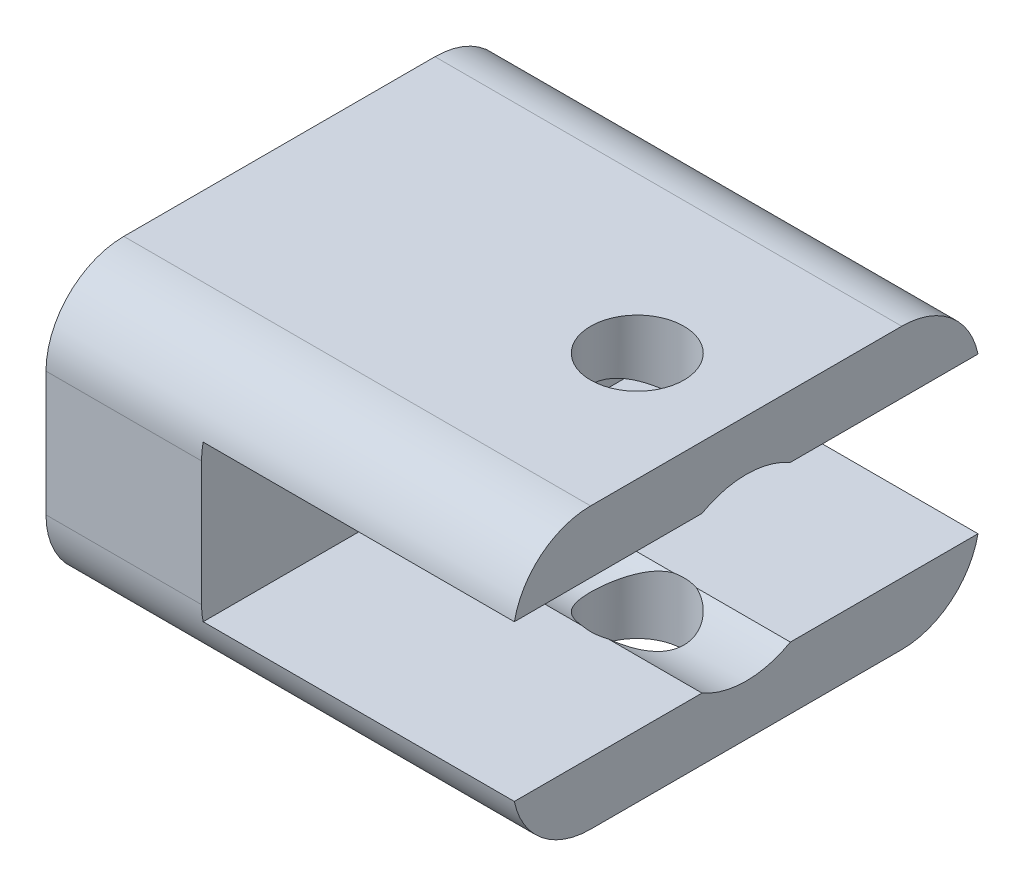
from build123d import *

# Parameters (mm, degrees)
ESQUISSE1_W                        = 30
ESQUISSE1_H                        = 30
BOSS_EXTRU_1_DEPTH                 = 4
ENL_V_MAT_EXTRU_1_DEPTH            = 12.400000001
ESQUISSE3_W                        = 10
ESQUISSE3_H                        = 30
BOSS_EXTRU_2_DEPTH                 = 14
ESQUISSE4_W                        = 30
ESQUISSE4_H                        = 4
BOSS_EXTRU_3_DEPTH                 = 20
ESQUISSE5_R                        = 5.75
ENL_V_MAT_EXTRU_2_DEPTH            = 20
DIAM_TRE_DU_PER_AGE_6_0_6_1_REACH  = 20
DIAM_TRE_DU_PER_AGE_6_0_6_1_BORE_R = 3
DIAM_TRE_DU_PER_AGE_6_0_6_2_D      = 6
DIAM_TRE_DU_PER_AGE_6_0_6_2_DEPTH  = 18
CONG_2_R                           = 5


with BuildPart() as part:
    # Esquisse1 → Boss.-Extru.1 (new body)
    with BuildSketch(Plane.XZ):
        with Locations((15, 15)):
            Rectangle(ESQUISSE1_W, ESQUISSE1_H)
    extrude(amount=-BOSS_EXTRU_1_DEPTH)

    # Esquisse2 → Enlèv. mat.-Extru.1 (cut)
    with BuildSketch(Plane(origin=(22.400000001, 0, 0), x_dir=(0, 0, -1), z_dir=(1, 0, 0))):
        with BuildLine():
            Line((-12.060612309, 4), (-17.939387691, 4))
            ThreePointArc((-17.939387691, 4), (-15, 3.2), (-12.060612309, 4))
        make_face()
    extrude(amount=-ENL_V_MAT_EXTRU_1_DEPTH, mode=Mode.SUBTRACT)

    # Esquisse3 → Boss.-Extru.2 (add)
    with BuildSketch(Plane(origin=(0, 4, 0), x_dir=(-1, 0, 0), z_dir=(0, 1, 0))):
        with Locations((-5, 15)):
            Rectangle(ESQUISSE3_W, ESQUISSE3_H)
    extrude(amount=BOSS_EXTRU_2_DEPTH)

    # Esquisse4 → Boss.-Extru.3 (add)
    with BuildSketch(Plane(origin=(10, 0, 0), x_dir=(0, 0, -1), z_dir=(1, 0, 0))):
        with Locations((-15, 16)):
            Rectangle(ESQUISSE4_W, ESQUISSE4_H)
    extrude(amount=BOSS_EXTRU_3_DEPTH)

    # Esquisse5 → Enlèv. mat.-Extru.2 (cut)
    with BuildSketch(Plane(origin=(30, 0, 0), x_dir=(0, 0, -1), z_dir=(1, 0, 0))):
        with Locations((-15, 9)):
            Circle(ESQUISSE5_R)
    extrude(amount=-ENL_V_MAT_EXTRU_2_DEPTH, mode=Mode.SUBTRACT)

    # Esquisse7 → Enlèvement de matière-Révolution1 (revolve, cut)
    with BuildSketch(Plane(origin=(0, 0, 15), x_dir=(-1, 0, 0), z_dir=(0, 0, -1)), mode=Mode.PRIVATE) as enl_vement_de_mati_re_r_volution1_sk:
        Polygon((-10, 14.75), (-10, 9), (0, 9), (0, 11.75), (-7, 11.75), align=None)
    revolve(enl_vement_de_mati_re_r_volution1_sk.sketch.rotate(Axis((10, 9, 15), (-1, 0, 0)), 29.591845794), axis=Axis((10, 9, 15), (-1, 0, 0)), mode=Mode.SUBTRACT)  # turned: the seam where the file's is

    # Diamètre du perçage Ø6.0 (6)1 bore → Diamètre du perçage Ø6.0 (6)1 (cut, up to next)
    with BuildSketch(Plane(origin=(0, 18, 0), x_dir=(1, 0, 0), z_dir=(0, 1, 0)), mode=Mode.PRIVATE) as diam_tre_du_per_age_6_0_6_1_sk1:
        with Locations((23, -15)):
            Circle(DIAM_TRE_DU_PER_AGE_6_0_6_1_BORE_R)
    diam_tre_du_per_age_6_0_6_1_tool1 = extrude(diam_tre_du_per_age_6_0_6_1_sk1.sketch, amount=-DIAM_TRE_DU_PER_AGE_6_0_6_1_REACH, mode=Mode.PRIVATE) & part.part
    add(diam_tre_du_per_age_6_0_6_1_tool1.solids().sort_by_distance((23, 18, 15))[0], mode=Mode.SUBTRACT)

    # Diamètre du perçage Ø6.0 (6)2
    with Locations(Plane(origin=(0, 0, 0), x_dir=(-1, 0, 0), z_dir=(0, -1, 0))):
        with Locations((-23, -15)):
            Hole(DIAM_TRE_DU_PER_AGE_6_0_6_2_D / 2, depth=DIAM_TRE_DU_PER_AGE_6_0_6_2_DEPTH)

    # Congé2
    cong_2_edges = [part.edges().sort_by_distance(p)[0] for p in [
        (15, 18, 0),
        (15, 0, 0),
        (15, 0, 30),
        (15, 18, 30),
    ]]
    fillet(cong_2_edges, radius=CONG_2_R)


solid = part.part
